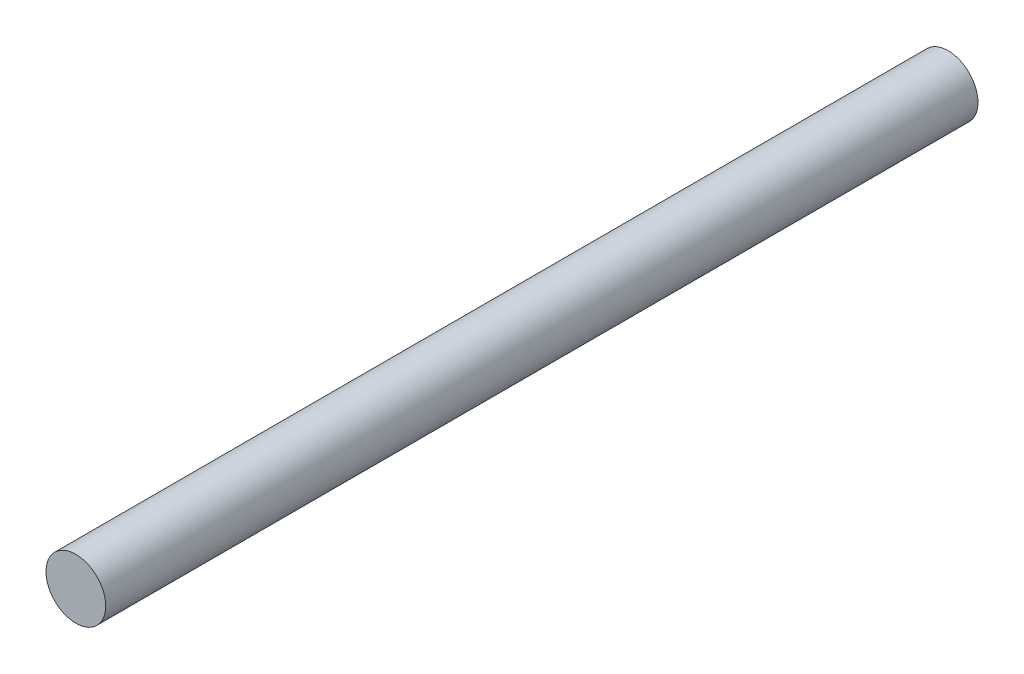
from build123d import *

# Parameters (mm, degrees)
SKETCH1_R           = 2.5
BOSS_EXTRUDE1_DEPTH = 73


with BuildPart() as part:
    # Sketch1 → Boss-Extrude1 (new body)
    with BuildSketch(Plane.XY):
        Circle(SKETCH1_R)
    extrude(amount=BOSS_EXTRUDE1_DEPTH)


solid = part.part
